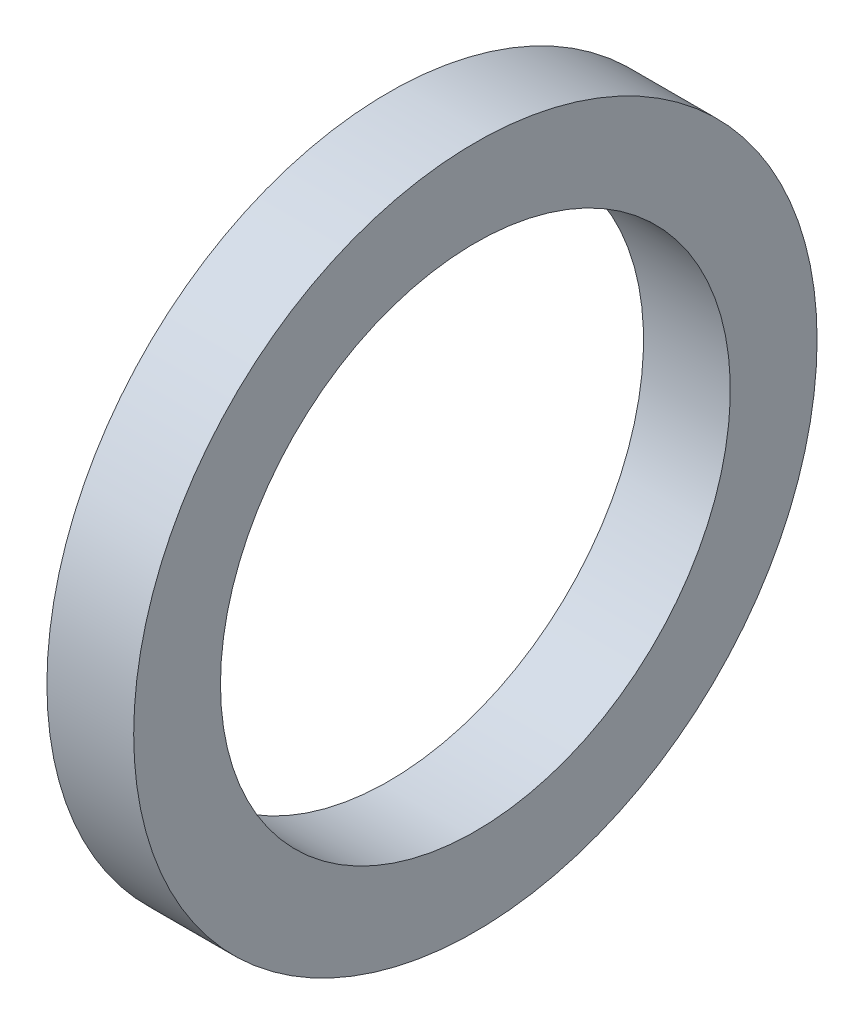
from build123d import *

# Parameters (mm, degrees)
SKETCH1_W = 2.032
SKETCH1_H = 2.032


with BuildPart() as part:
    # Sketch1 → Revolve1 (revolve)
    with BuildSketch(Plane.XY, mode=Mode.PRIVATE) as revolve1_sk:
        with Locations((1.016, -6.985)):
            Rectangle(SKETCH1_W, SKETCH1_H)
    revolve(revolve1_sk.sketch.rotate(Axis((-43.716580756, 0, 0), (1, 0, 0)), 270), axis=Axis((-43.716580756, 0, 0), (1, 0, 0)))  # turned: the seam where the file's is


solid = part.part
